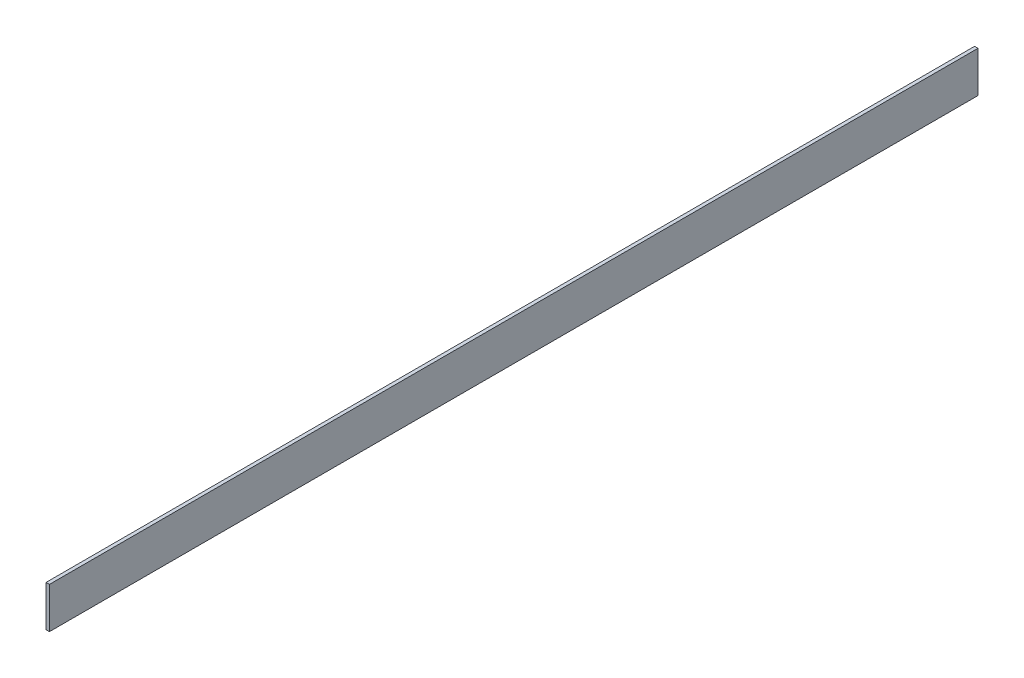
from build123d import *

# Parameters (mm, degrees)
SKETCH1_W           = 3.175
SKETCH1_H           = 863.6
BOSS_EXTRUDE1_DEPTH = 38.1


with BuildPart() as part:
    # Sketch1 → Boss-Extrude1 (new body)
    with BuildSketch(Plane(origin=(0, 0, 0), x_dir=(1, 0, 0), z_dir=(0, 1, 0))):
        with Locations((1.5875, 431.8)):
            Rectangle(SKETCH1_W, SKETCH1_H)
    extrude(amount=BOSS_EXTRUDE1_DEPTH)


solid = part.part
